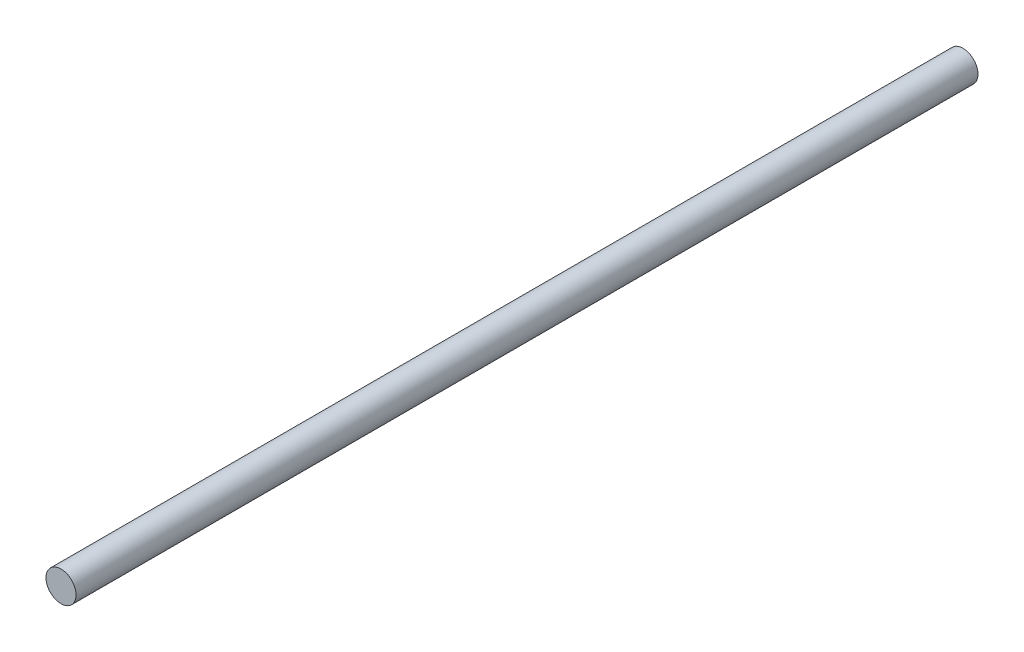
from build123d import *

# Parameters (mm, degrees)
SKETCH1_R           = 2.5
BOSS_EXTRUDE1_DEPTH = 150


with BuildPart() as part:
    # Sketch1 → Boss-Extrude1 (new body)
    with BuildSketch(Plane.XY):
        Circle(SKETCH1_R)
    extrude(amount=BOSS_EXTRUDE1_DEPTH)


solid = part.part
